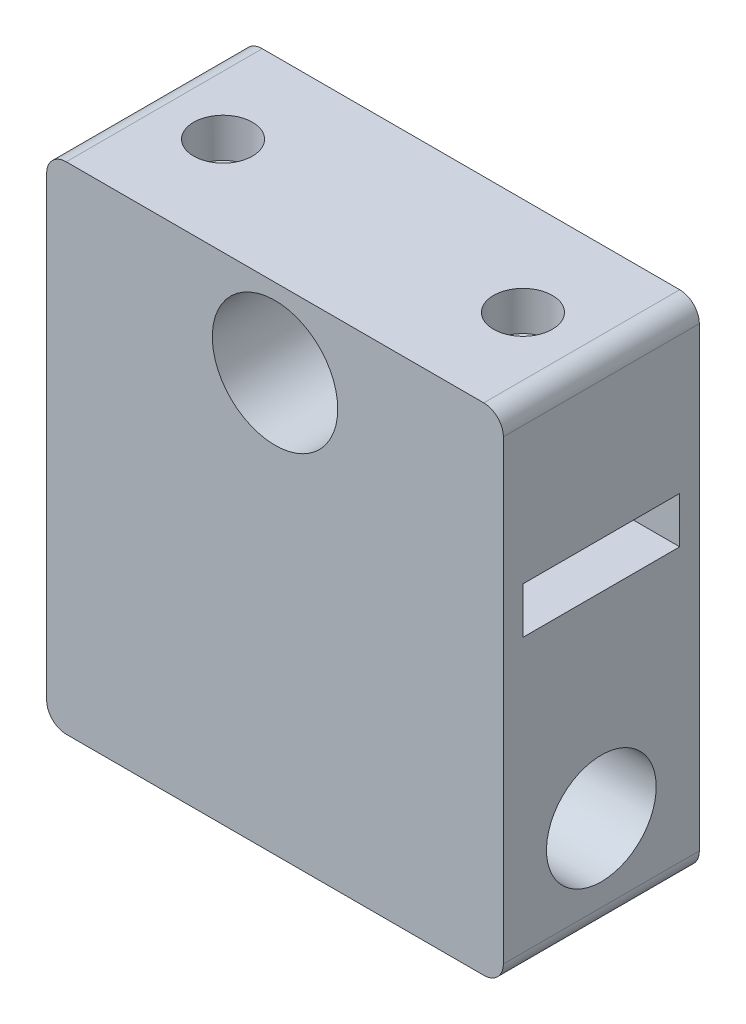
from build123d import *

# Parameters (mm, degrees)
SKETCH1_W           = 29.59652174
SKETCH1_H           = 50.8
SKETCH1_R           = 4.064
BOSS_EXTRUDE1_DEPTH = 12.7
SKETCH2_W           = 10.16
SKETCH2_H           = 3
CUT_EXTRUDE1_DEPTH  = 30.48
SKETCH3_R           = 3.556
CUT_EXTRUDE2_DEPTH  = 45.72
SKETCH4_R           = 1.143
CUT_EXTRUDE3_DEPTH  = 14.290068122
SKETCH5_R           = 1.905
CUT_EXTRUDE4_DEPTH  = 5.08
SKETCH7_W           = 12.7
SKETCH7_H           = 11.050531838
CUT_EXTRUDE5_DEPTH  = 62.484
SKETCH8_W           = 29.59652174
SKETCH8_H           = 2.54
CUT_EXTRUDE6_DEPTH  = 62.484
SKETCH9_W           = 12.7
SKETCH9_H           = 5.08
CUT_EXTRUDE7_DEPTH  = 62.484
FILLET1_R           = 1.27


with BuildPart() as part:
    # Sketch1 → Boss-Extrude1 (new body)
    with BuildSketch(Plane.XY):
        Rectangle(SKETCH1_W, SKETCH1_H)
        with Locations((0, 17.78)):
            Circle(SKETCH1_R, mode=Mode.SUBTRACT)
    extrude(amount=BOSS_EXTRUDE1_DEPTH)

    # Sketch2 → Cut-Extrude1 (cut)
    with BuildSketch(Plane.ZY.offset(14.79826087)):
        with Locations((6.35, 11.2)):
            Rectangle(SKETCH2_W, SKETCH2_H)
    extrude(amount=-CUT_EXTRUDE1_DEPTH, mode=Mode.SUBTRACT)

    # Sketch3 → Cut-Extrude2 (cut)
    with BuildSketch(Plane.ZY.offset(14.79826087)):
        with Locations((6.35, -3)):
            Circle(SKETCH3_R)
    extrude(amount=-CUT_EXTRUDE2_DEPTH, mode=Mode.SUBTRACT)

    # Sketch4 → Cut-Extrude3 (cut)
    with BuildSketch(Plane(origin=(0, 25.4, 0), x_dir=(1, 0, 0), z_dir=(0, 1, 0))):
        with Locations((9.71826087, -6.35)):
            Circle(SKETCH4_R)
        with Locations((-9.71826087, -6.35)):
            Circle(SKETCH4_R)
    extrude(amount=-CUT_EXTRUDE3_DEPTH, mode=Mode.SUBTRACT)

    # Sketch5 → Cut-Extrude4 (cut)
    with BuildSketch(Plane(origin=(0, 25.4, 0), x_dir=(1, 0, 0), z_dir=(0, 1, 0))):
        with Locations((-9.71826087, -6.35)):
            Circle(SKETCH5_R)
        with Locations((9.71826087, -6.35)):
            Circle(SKETCH5_R)
    extrude(amount=-CUT_EXTRUDE4_DEPTH, mode=Mode.SUBTRACT)

    # Sketch7 → Cut-Extrude5 (cut)
    with BuildSketch(Plane.ZY.offset(14.79826087)):
        with Locations((6.35, -19.874734081)):
            Rectangle(SKETCH7_W, SKETCH7_H)
    extrude(amount=-CUT_EXTRUDE5_DEPTH, mode=Mode.SUBTRACT)

    # Sketch8 → Cut-Extrude6 (cut)
    with BuildSketch(Plane.XY.offset(12.7)):
        with Locations((0, 24.13)):
            Rectangle(SKETCH8_W, SKETCH8_H)
    extrude(amount=-CUT_EXTRUDE6_DEPTH, mode=Mode.SUBTRACT)

    # Sketch9 → Cut-Extrude7 (cut)
    with BuildSketch(Plane.ZY.offset(14.79826087)):
        with Locations((6.35, -11.809468162)):
            Rectangle(SKETCH9_W, SKETCH9_H)
    extrude(amount=-CUT_EXTRUDE7_DEPTH, mode=Mode.SUBTRACT)

    # Fillet1
    fillet1_edges = [part.edges().sort_by_distance(p)[0] for p in [
        (14.79826087, -9.269468162, 6.35),
        (-14.79826087, -9.269468162, 6.35),
        (-14.79826087, 22.86, 6.35),
        (14.79826087, 22.86, 6.35),
    ]]
    fillet(fillet1_edges, radius=FILLET1_R)


solid = part.part
